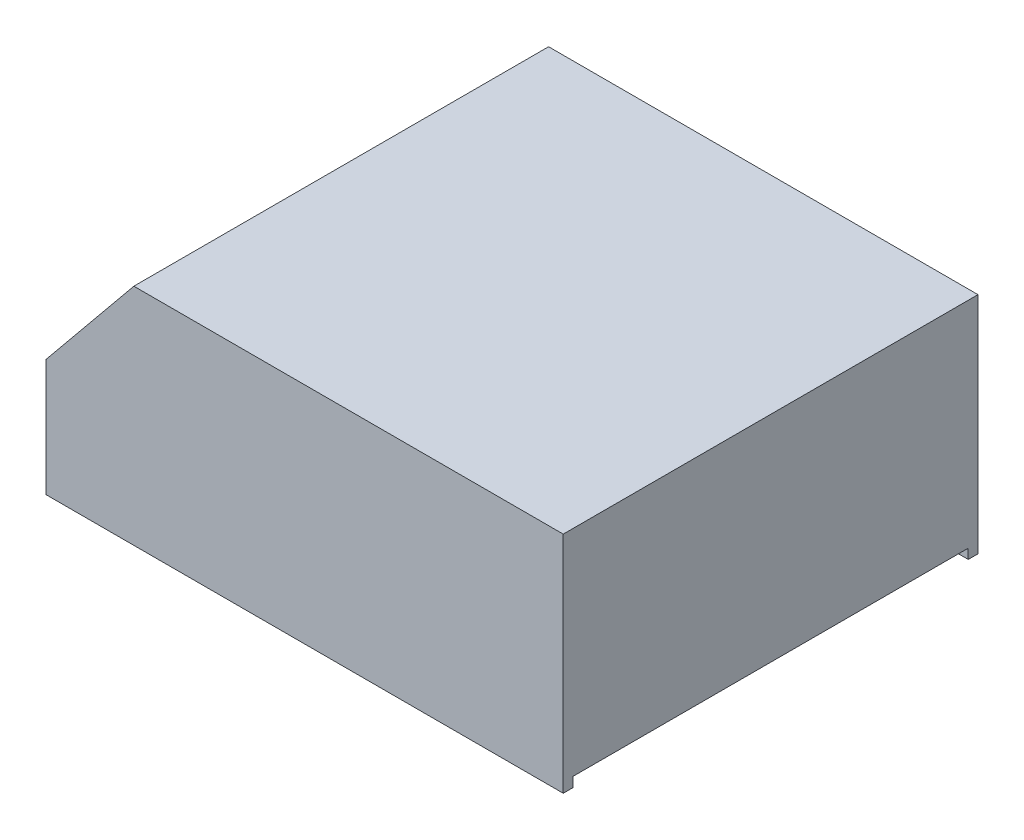
from build123d import *

# Parameters (mm, degrees)
SALIENTE_EXTRUIR1_DEPTH = 85
CROQUIS3_W              = 18
CROQUIS3_H              = 26
CORTAR_EXTRUIR1_DEPTH   = 47
VACIADO1_T              = -2
SALIENTE_EXTRUIR2_REACH = 48
CROQUIS4_R              = 4
CROQUIS5_R              = 4
CORTAR_EXTRUIR2_DEPTH   = 2
CROQUIS8_W              = 2
CROQUIS8_H              = 81
CORTAR_EXTRUIR3_DEPTH   = 2
CROQUIS9_R              = 1.5
CORTAR_EXTRUIR4_DEPTH   = 10


with BuildPart() as part:
    # Croquis2 → Saliente-Extruir1 (new body)
    with BuildSketch(Plane.XY):
        Polygon((0, 0), (0, 46), (-88, 46), (-106, 24), (-106, 0), align=None)
    extrude(amount=SALIENTE_EXTRUIR1_DEPTH)

    # Croquis3 → Cortar-Extruir1 (cut, through all)
    with BuildSketch(Plane.XZ):
        with Locations((-97, 42.5)):
            Rectangle(CROQUIS3_W, CROQUIS3_H)
    extrude(amount=-CORTAR_EXTRUIR1_DEPTH, mode=Mode.SUBTRACT)

    # Vaciado1
    vaciado1_openings = [part.faces().sort_by_distance(p)[0] for p in [
        (-75, 0, 42.5),
    ]]
    offset(amount=VACIADO1_T, openings=vaciado1_openings, kind=Kind.INTERSECTION)

    # Croquis4 → Saliente-Extruir2 (add, up to next)
    with BuildSketch(Plane.XZ, mode=Mode.PRIVATE) as saliente_extruir2_sk1:
        with Locations((-95, 69.6)):
            Circle(CROQUIS4_R)
    saliente_extruir2_tool1 = extrude(saliente_extruir2_sk1.sketch, amount=-SALIENTE_EXTRUIR2_REACH, mode=Mode.PRIVATE) - part.part
    add(saliente_extruir2_tool1.solids().sort_by_distance((-95, 0, 69.6))[0])
    # Croquis4 → Saliente-Extruir2 (add, up to next)
    with BuildSketch(Plane.XZ, mode=Mode.PRIVATE) as saliente_extruir2_sk2:
        with Locations((-95, 14.1)):
            Circle(CROQUIS4_R)
    saliente_extruir2_tool2 = extrude(saliente_extruir2_sk2.sketch, amount=-SALIENTE_EXTRUIR2_REACH, mode=Mode.PRIVATE) - part.part
    add(saliente_extruir2_tool2.solids().sort_by_distance((-95, 0, 14.1))[0])

    # Croquis5 → Cortar-Extruir2 (cut)
    with BuildSketch(Plane.XZ):
        with Locations((-95, 69.6)):
            Circle(CROQUIS5_R)
        with Locations((-95, 14.1)):
            Circle(CROQUIS5_R)
    extrude(amount=-CORTAR_EXTRUIR2_DEPTH, mode=Mode.SUBTRACT)

    # Croquis8 → Cortar-Extruir3 (cut)
    with BuildSketch(Plane.XZ):
        with Locations((-1, 42.5)):
            Rectangle(CROQUIS8_W, CROQUIS8_H)
    extrude(amount=-CORTAR_EXTRUIR3_DEPTH, mode=Mode.SUBTRACT)

    # Croquis9 → Cortar-Extruir4 (cut)
    with BuildSketch(Plane.XZ.offset(-2)):
        with Locations((-95, 69.6)):
            Circle(CROQUIS9_R)
        with Locations((-95, 14.1)):
            Circle(CROQUIS9_R)
    extrude(amount=-CORTAR_EXTRUIR4_DEPTH, mode=Mode.SUBTRACT)


solid = part.part
